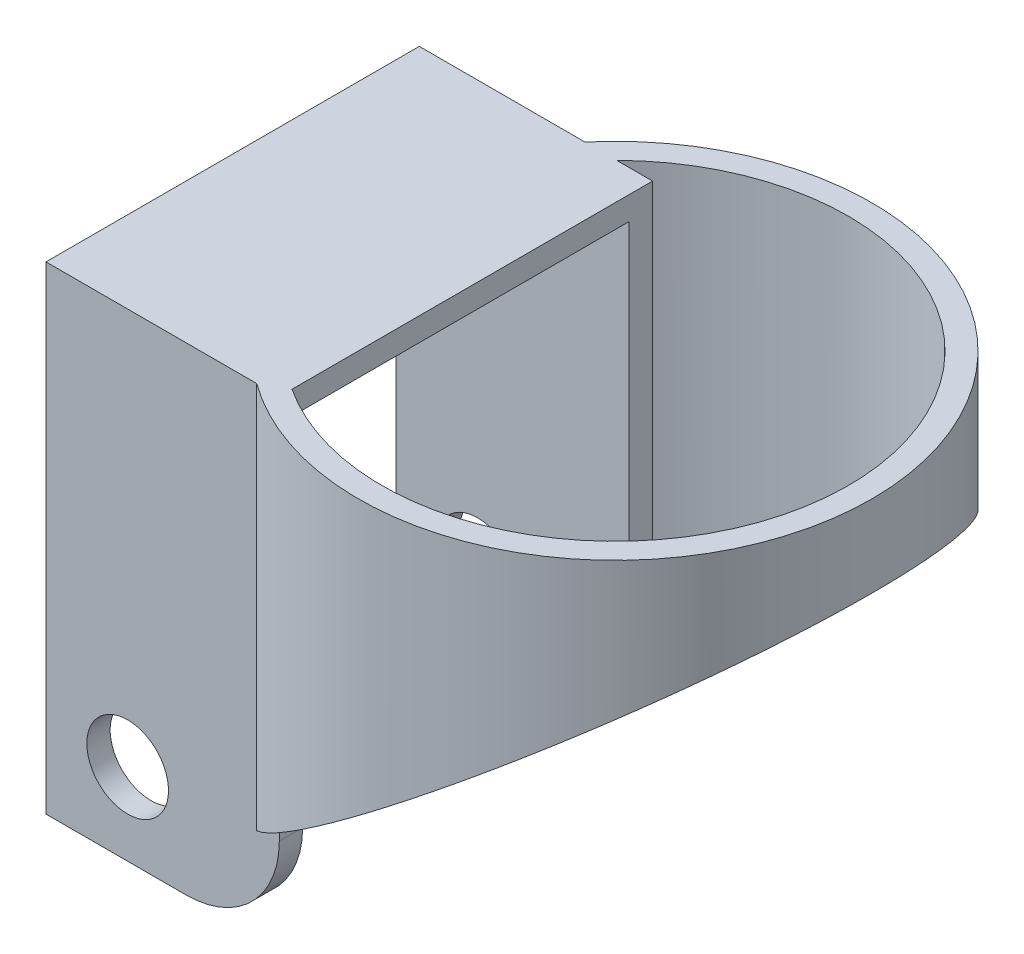
from build123d import *

# Parameters (mm, degrees)
SKETCH1_R               = 22
SKETCH1_R_2             = 20
BOSS_EXTRUDE1_DEPTH     = 40
CUT_EXTRUDE1_DEPTH      = 23
CUT_EXTRUDE1_DEPTH_BACK = 23
BOSS_EXTRUDE2_DEPTH     = 20
SKETCH4_W               = 28
SKETCH4_H               = 39
CUT_EXTRUDE2_DEPTH      = 32
SKETCH5_R               = 3.5
CUT_EXTRUDE3_DEPTH      = 8.79196205
CUT_EXTRUDE3_DEPTH_BACK = 37.20803795
FILLET1_R               = 8


with BuildPart() as part:
    # Sketch1 → Boss-Extrude1 (new body)
    with BuildSketch(Plane(origin=(0, 0, 0), x_dir=(1, 0, 0), z_dir=(0, 1, 0))):
        Circle(SKETCH1_R)
        Circle(SKETCH1_R_2, mode=Mode.SUBTRACT)
    extrude(amount=BOSS_EXTRUDE1_DEPTH)

    # Sketch2 → Cut-Extrude1 (cut, two sides)
    with BuildSketch(Plane.XY) as cut_extrude1_sk:
        Polygon((22, 33), (-22, 0), (22, 0), align=None)
    extrude(amount=CUT_EXTRUDE1_DEPTH, mode=Mode.SUBTRACT)
    extrude(cut_extrude1_sk.sketch, amount=-CUT_EXTRUDE1_DEPTH_BACK, mode=Mode.SUBTRACT)

    # Sketch3 → Boss-Extrude2 (add)
    with BuildSketch(Plane(origin=(-31, 0, 0), x_dir=(0, 0, -1), z_dir=(1, 0, 0))):
        Polygon((14.20803795, 40), (-17.79196205, 40), (-17.79196205, -1), (-15.79196205, -1), (-15.79196205, 1), (-15.79196205, 38), (12.20803795, 38), (12.20803795, 1), (12.20803795, -1), (14.20803795, -1), align=None)
    extrude(amount=BOSS_EXTRUDE2_DEPTH)

    # Sketch4 → Cut-Extrude2 (cut, through all)
    with BuildSketch(Plane(origin=(0, 0, 0), x_dir=(0, 0, -1), z_dir=(1, 0, 0))):
        with Locations((-1.79196205, 18.5)):
            Rectangle(SKETCH4_W, SKETCH4_H)
    extrude(amount=-CUT_EXTRUDE2_DEPTH, mode=Mode.SUBTRACT)

    # Sketch5 → Cut-Extrude3 (cut, two sides)
    with BuildSketch(Plane(origin=(0, 0, -14.20803795), x_dir=(-1, 0, 0), z_dir=(0, 0, -1))) as cut_extrude3_sk:
        with Locations((24, 6)):
            Circle(SKETCH5_R)
    extrude(amount=CUT_EXTRUDE3_DEPTH, mode=Mode.SUBTRACT)
    extrude(cut_extrude3_sk.sketch, amount=-CUT_EXTRUDE3_DEPTH_BACK, mode=Mode.SUBTRACT)

    # Fillet1
    fillet1_edges = [part.edges().sort_by_distance(p)[0] for p in [
        (-11, -1, 16.79196205),
        (-11, -1, -13.20803795),
    ]]
    fillet(fillet1_edges, radius=FILLET1_R)


solid = part.part
